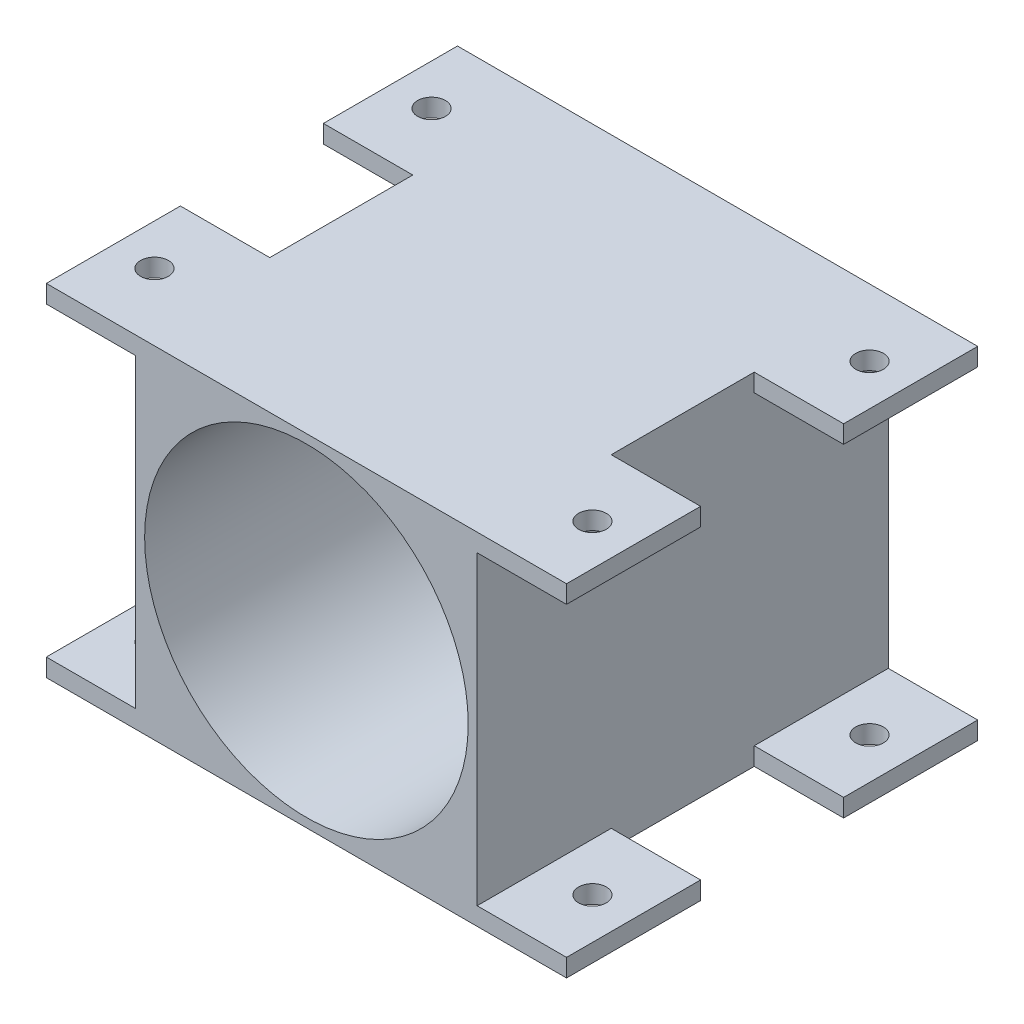
from build123d import *

# Parameters (mm, degrees)
SKETCH1_R           = 18.1
SKETCH1_R_2         = 1.55
SKETCH1_R_3         = 6.05
BOSS_EXTRUDE1_DEPTH = 1
SKETCH2_W           = 38.2
SKETCH2_H           = 38.2
SKETCH2_R           = 18.1
BOSS_EXTRUDE2_DEPTH = 46
SKETCH3_W           = 10
SKETCH3_H           = 15
SKETCH3_R           = 1.55
BOSS_EXTRUDE3_DEPTH = 2


with BuildPart() as part:
    # Sketch1 → Boss-Extrude1 (new body)
    with BuildSketch(Plane.XY):
        Circle(SKETCH1_R)
        with Locations((15, 0)):
            Circle(SKETCH1_R_2, mode=Mode.SUBTRACT)
        with Locations((7.5, 12.990381057)):
            Circle(SKETCH1_R_2, mode=Mode.SUBTRACT)
        with Locations((-7.5, 12.990381057)):
            Circle(SKETCH1_R_2, mode=Mode.SUBTRACT)
        with Locations((0, 6)):
            Circle(SKETCH1_R_3, mode=Mode.SUBTRACT)
        with Locations((-15, 0)):
            Circle(SKETCH1_R_2, mode=Mode.SUBTRACT)
        with Locations((7.5, -12.990381057)):
            Circle(SKETCH1_R_2, mode=Mode.SUBTRACT)
        with Locations((-7.5, -12.990381057)):
            Circle(SKETCH1_R_2, mode=Mode.SUBTRACT)
    extrude(amount=BOSS_EXTRUDE1_DEPTH)

    # Sketch2 → Boss-Extrude2 (add)
    with BuildSketch(Plane(origin=(0, 0, 0), x_dir=(-1, 0, 0), z_dir=(0, 0, -1))):
        Rectangle(SKETCH2_W, SKETCH2_H)
        Circle(SKETCH2_R, mode=Mode.SUBTRACT)
    extrude(amount=-BOSS_EXTRUDE2_DEPTH)

    # Sketch3 → Boss-Extrude3 (add)
    with BuildSketch(Plane.XZ.offset(19.1)):
        with Locations((24.1, 7.5)):
            Rectangle(SKETCH3_W, SKETCH3_H)
        with Locations((24.5, 7.5)):
            Circle(SKETCH3_R, mode=Mode.SUBTRACT)
        with Locations((24.1, 38.5)):
            Rectangle(SKETCH3_W, SKETCH3_H)
        with Locations((24.5, 38.5)):
            Circle(SKETCH3_R, mode=Mode.SUBTRACT)
        with Locations((-24.1, 38.5)):
            Rectangle(SKETCH3_W, SKETCH3_H)
        with Locations((-24.5, 38.5)):
            Circle(SKETCH3_R, mode=Mode.SUBTRACT)
        with Locations((-24.1, 7.5)):
            Rectangle(SKETCH3_W, SKETCH3_H)
        with Locations((-24.5, 7.5)):
            Circle(SKETCH3_R, mode=Mode.SUBTRACT)
    boss_extrude3 = extrude(amount=-BOSS_EXTRUDE3_DEPTH)

    # Mirror1: Boss-Extrude3 across plane
    add(boss_extrude3.mirror(Plane.ZX))


solid = part.part
